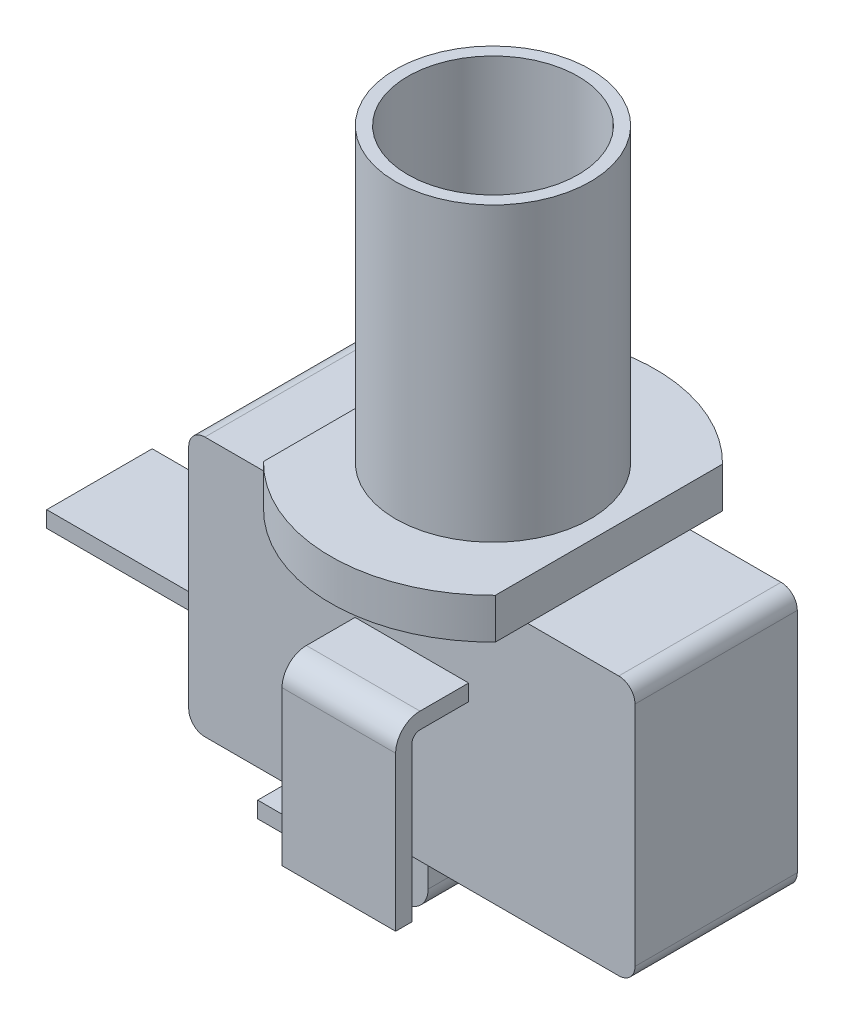
from build123d import *

# Parameters (mm, degrees)
BOSS_EXTRUDE1_DEPTH      = 5
BOSS_EXTRUDE1_DEPTH_BACK = 5
BOSS_EXTRUDE2_DEPTH      = 2.5
SKETCH3_W                = 1
SKETCH3_H                = 6.5
SKETCH6_W                = 6.5
SKETCH6_H                = 1
BOSS_EXTRUDE3_DEPTH      = 10.5
SKETCH7_W                = 7
SKETCH7_H                = 1
SKETCH9_R                = 6
BOSS_EXTRUDE4_DEPTH      = 18
SKETCH10_R               = 5.25
CUT_EXTRUDE1_DEPTH       = 20.5


with BuildPart() as part:
    # Sketch1 → Boss-Extrude1 (new body, two sides)
    with BuildSketch(Plane.XY) as boss_extrude1_sk:
        with BuildLine():
            Line((0, 1), (0, 15))
            ThreePointArc((0, 15), (0.292893219, 15.707106781), (1, 16))
            Line((1, 16), (26.5, 16))
            ThreePointArc((26.5, 16), (27.207106781, 15.707106781), (27.5, 15))
            Line((27.5, 15), (27.5, 1))
            ThreePointArc((27.5, 1), (27.207106781, 0.292893219), (26.5, 0))
            Line((26.5, 0), (1, 0))
            ThreePointArc((1, 0), (0.292893219, 0.292893219), (0, 1))
        make_face()
    extrude(amount=BOSS_EXTRUDE1_DEPTH)
    extrude(boss_extrude1_sk.sketch, amount=-BOSS_EXTRUDE1_DEPTH_BACK)

    # Sketch2 → Boss-Extrude2 (add)
    with BuildSketch(Plane(origin=(0, 16, 0), x_dir=(-1, 0, 0), z_dir=(0, 1, 0))):
        with BuildLine():
            Line((-20.891428429, 7), (-20.891428429, -7))
            ThreePointArc((-20.891428429, -7), (-13.75, -10), (-6.608571571, -7))
            Line((-6.608571571, -7), (-6.608571571, 7))
            ThreePointArc((-6.608571571, 7), (-13.75, 10), (-20.891428429, 7))
        make_face()
    extrude(amount=BOSS_EXTRUDE2_DEPTH)

    # Sweep1: sweep along a path in Sketch5
    with BuildLine(Plane.XY.offset(5)) as sweep1_path:
        Line((12, 0), (12, -3))
        ThreePointArc((12, -3), (11.853553391, -3.353553391), (11.5, -3.5))
        Line((11.5, -3.5), (2.5, -3.5))
    # Sketch3 → Sweep1 (sweep)
    with BuildSketch(Plane.XZ):
        with Locations((12.5, 0)):
            Rectangle(SKETCH3_W, SKETCH3_H)
    sweep(path=sweep1_path.line)

    # Sketch6 → Boss-Extrude3 (add)
    with BuildSketch(Plane.ZY):
        with Locations((0, 5)):
            Rectangle(SKETCH6_W, SKETCH6_H)
    extrude(amount=BOSS_EXTRUDE3_DEPTH)

    # Sweep2: sweep along a path in Sketch8
    with BuildLine(Plane.ZY) as sweep2_path:
        Line((5, 10), (8, 10))
        ThreePointArc((8, 10), (8.353553391, 9.853553391), (8.5, 9.5))
        Line((8.5, 9.5), (8.5, 0))
    # Sketch7 → Sweep2 (sweep)
    with BuildSketch(Plane.XY.offset(5)):
        with Locations((13.75, 10.5)):
            Rectangle(SKETCH7_W, SKETCH7_H)
    sweep2 = sweep(path=sweep2_path.line)

    # Mirror1: Sweep2 across plane
    add(sweep2.mirror(Plane.XY))

    # Sketch9 → Boss-Extrude4 (add)
    with BuildSketch(Plane(origin=(0, 18.5, 0), x_dir=(-1, 0, 0), z_dir=(0, 1, 0))):
        with Locations((-13.75, 0)):
            Circle(SKETCH9_R)
    extrude(amount=BOSS_EXTRUDE4_DEPTH)

    # Sketch10 → Cut-Extrude1 (cut)
    with BuildSketch(Plane(origin=(0, 36.5, 0), x_dir=(1, 0, 0), z_dir=(0, 1, 0))):
        with Locations((13.75, 0)):
            Circle(SKETCH10_R)
    extrude(amount=-CUT_EXTRUDE1_DEPTH, mode=Mode.SUBTRACT)


solid = part.part
